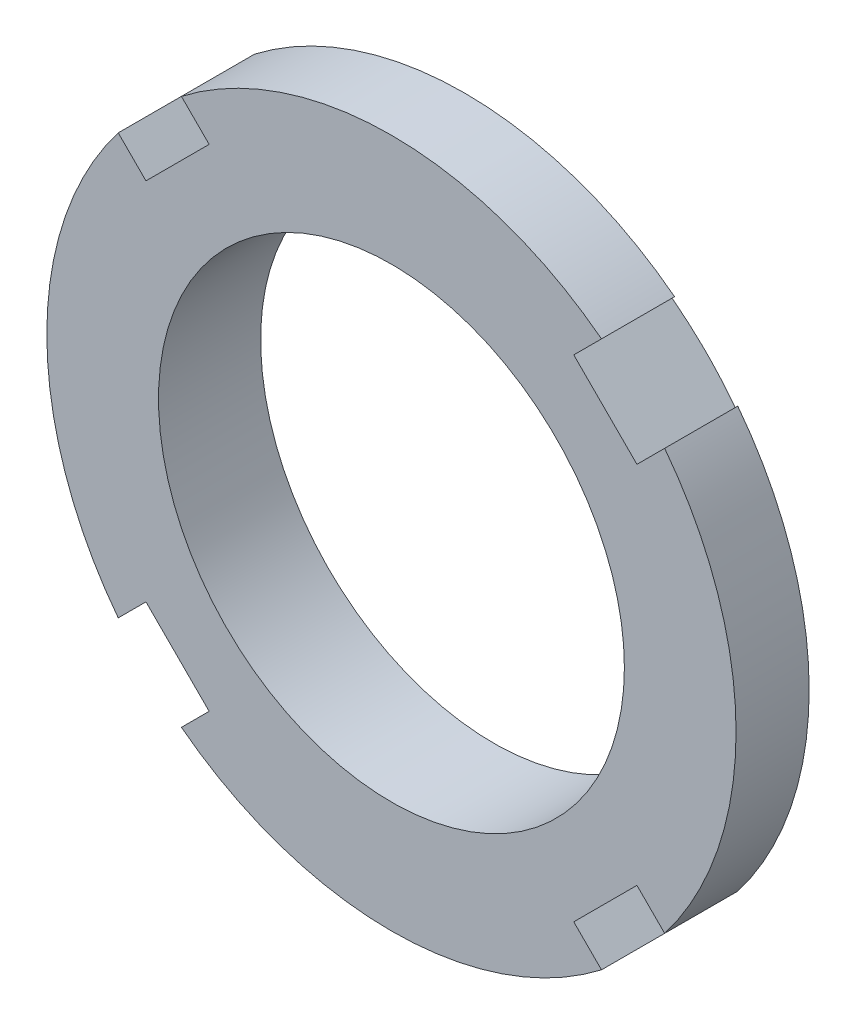
from build123d import *

# Parameters (mm, degrees)
SKETCH1_R          = 27
SKETCH1_R_2        = 18.25
EXTRUDE1_DEPTH     = 8
CUT_EXTRUDE1_DEPTH = 9
CIRPATTERN1_COUNT  = 4


with BuildPart() as part:
    # Sketch1 → Extrude1 (new body)
    with BuildSketch(Plane.XY):
        Circle(SKETCH1_R)
        Circle(SKETCH1_R_2, mode=Mode.SUBTRACT)
    extrude(amount=EXTRUDE1_DEPTH)

    # Sketch2 → Cut-Extrude1 (cut, through all)
    with BuildSketch(Plane.XY.offset(8)):
        with BuildLine():
            Line((16.455921283, 21.405668752), (14.28355698, 19.233304448))
            Line((14.28355698, 19.233304448), (19.233304448, 14.28355698))
            Line((19.233304448, 14.28355698), (21.405668752, 16.455921283))
            ThreePointArc((21.405668752, 16.455921283), (19.091883092, 19.091883092), (16.455921283, 21.405668752))
        make_face()
    cut_extrude1 = extrude(amount=-CUT_EXTRUDE1_DEPTH, mode=Mode.SUBTRACT)

    # CirPattern1: Cut-Extrude1 ×4 about axis
    cirpattern1_axis = Axis((0, 0, 0), (0, 0, 1))
    for i in range(1, CIRPATTERN1_COUNT):
        add(cut_extrude1.rotate(cirpattern1_axis, i * 360 / CIRPATTERN1_COUNT), mode=Mode.SUBTRACT)

    # Sketch3 → Cut-Revolve1 (revolve, cut)
    with BuildSketch(Plane(origin=(0, 0, 0), x_dir=(1, 0, 0), z_dir=(0, 1, 0))):
        Polygon((27, 0), (23.5, 0), (27, -2.272926576), align=None)
    revolve(axis=Axis((0, 0, 0), (0, 0, -1)), mode=Mode.SUBTRACT)


solid = part.part
